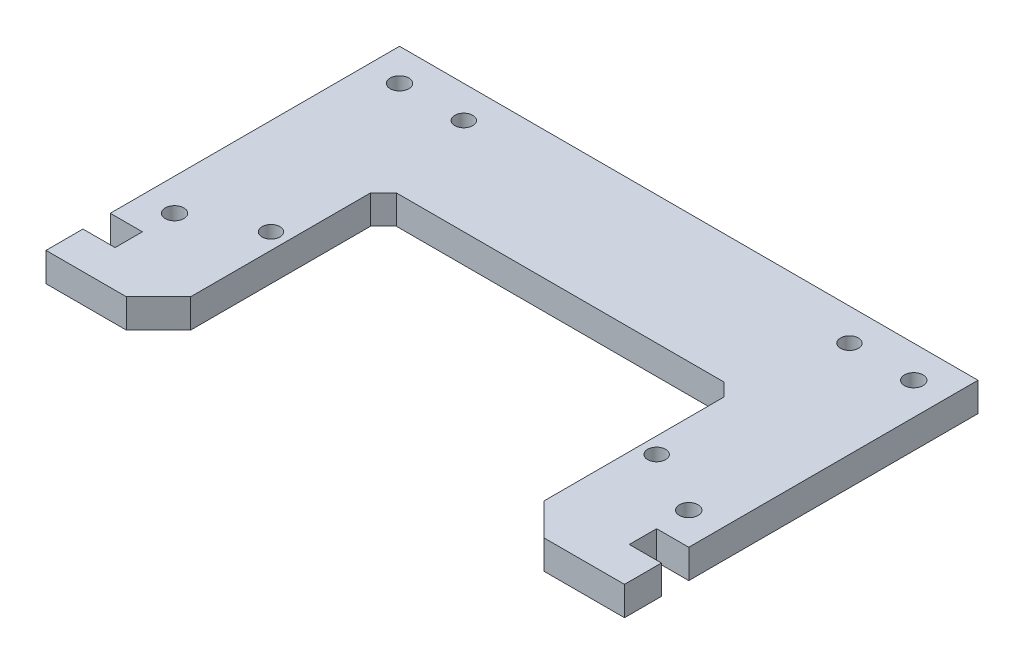
from build123d import *

# Parameters (mm, degrees)
SKETCH1_W           = 90
SKETCH1_H           = 55
SKETCH1_R           = 1.45
BOSS_EXTRUDE1_DEPTH = 4.5
SKETCH2_W           = 55
SKETCH2_H           = 35
CUT_EXTRUDE1_DEPTH  = 5.5
SKETCH3_W           = 5
SKETCH3_H           = 4.25
CUT_EXTRUDE2_DEPTH  = 5.5
SKETCH4_R           = 1.4
CUT_EXTRUDE3_DEPTH  = 5.5
CHAMFER1_SIZE       = 5
CHAMFER2_SIZE       = 2


with BuildPart() as part:
    # Sketch1 → Boss-Extrude1 (new body)
    with BuildSketch(Plane(origin=(0, 0, 0), x_dir=(1, 0, 0), z_dir=(0, 1, 0))):
        with Locations((0, -27.5)):
            Rectangle(SKETCH1_W, SKETCH1_H)
        with Locations((-40, -40)):
            Circle(SKETCH1_R, mode=Mode.SUBTRACT)
        with Locations((-40, -5)):
            Circle(SKETCH1_R, mode=Mode.SUBTRACT)
        with Locations((40, -40)):
            Circle(SKETCH1_R, mode=Mode.SUBTRACT)
        with Locations((40, -5)):
            Circle(SKETCH1_R, mode=Mode.SUBTRACT)
    extrude(amount=BOSS_EXTRUDE1_DEPTH)

    # Sketch2 → Cut-Extrude1 (cut, through all)
    with BuildSketch(Plane(origin=(0, 4.5, 0), x_dir=(1, 0, 0), z_dir=(0, 1, 0))):
        with Locations((0, -37.5)):
            Rectangle(SKETCH2_W, SKETCH2_H)
    extrude(amount=-CUT_EXTRUDE1_DEPTH, mode=Mode.SUBTRACT)

    # Sketch3 → Cut-Extrude2 (cut, through all)
    with BuildSketch(Plane(origin=(0, 4.5, 0), x_dir=(1, 0, 0), z_dir=(0, 1, 0))):
        with Locations((-42.5, -47.125)):
            Rectangle(SKETCH3_W, SKETCH3_H)
        with Locations((42.5, -47.125)):
            Rectangle(SKETCH3_W, SKETCH3_H)
    extrude(amount=-CUT_EXTRUDE2_DEPTH, mode=Mode.SUBTRACT)

    # Sketch4 → Cut-Extrude3 (cut, through all)
    with BuildSketch(Plane(origin=(0, 4.5, 0), x_dir=(1, 0, 0), z_dir=(0, 1, 0))):
        with Locations((-30, -35)):
            Circle(SKETCH4_R)
        with Locations((-30, -5)):
            Circle(SKETCH4_R)
    cut_extrude3 = extrude(amount=-CUT_EXTRUDE3_DEPTH, mode=Mode.SUBTRACT)

    # Mirror1: Cut-Extrude3 across plane
    add(cut_extrude3.mirror(Plane(origin=(0, 0, 0), x_dir=(0, 0, 1), z_dir=(1, 0, 0))), mode=Mode.SUBTRACT)

    # Chamfer1
    chamfer1_edges = [part.edges().sort_by_distance(p)[0] for p in [
        (27.5, 2.25, 55),
        (-27.5, 2.25, 55),
    ]]
    chamfer(chamfer1_edges, length=CHAMFER1_SIZE)

    # Chamfer2
    chamfer2_edges = [part.edges().sort_by_distance(p)[0] for p in [
        (27.5, 2.25, 20),
        (-27.5, 2.25, 20),
    ]]
    chamfer(chamfer2_edges, length=CHAMFER2_SIZE)


solid = part.part
